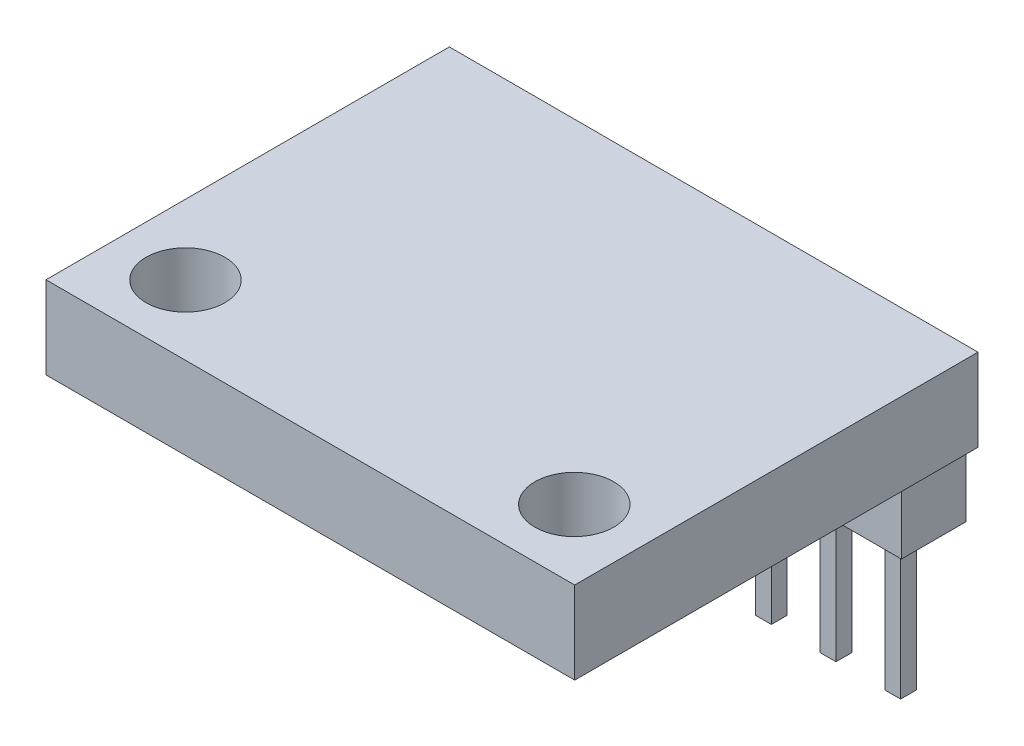
from build123d import *

# Parameters (mm, degrees)
SKETCH1_W           = 20.7772
SKETCH1_H           = 15.8496
SKETCH1_R           = 1.5494
BOSS_EXTRUDE2_DEPTH = 3.2385
SKETCH2_W           = 20.4978
SKETCH2_H           = 2.54
BOSS_EXTRUDE3_DEPTH = 2.4384
SKETCH3_W           = 0.6223
SKETCH3_H           = 0.6223
BOSS_EXTRUDE4_DEPTH = 5.7404


with BuildPart() as part:
    # Sketch1 → Boss-Extrude2 (new body)
    with BuildSketch(Plane(origin=(0, 0, 0), x_dir=(1, 0, 0), z_dir=(0, 1, 0))):
        with Locations((0, 0.7239)):
            Rectangle(SKETCH1_W, SKETCH1_H)
        with Locations((7.64032, -4.46786)):
            Circle(SKETCH1_R, mode=Mode.SUBTRACT)
        with Locations((-7.64032, -4.46786)):
            Circle(SKETCH1_R, mode=Mode.SUBTRACT)
    extrude(amount=BOSS_EXTRUDE2_DEPTH)

    # Sketch2 → Boss-Extrude3 (add)
    with BuildSketch(Plane(origin=(0, 0, 0), x_dir=(1, 0, 0), z_dir=(0, 1, 0))):
        with Locations((0, 7.0485)):
            Rectangle(SKETCH2_W, SKETCH2_H)
    extrude(amount=-BOSS_EXTRUDE3_DEPTH)

    # Sketch3 → Boss-Extrude4 (add)
    with BuildSketch(Plane.XZ.offset(2.4384)):
        with Locations((-6.29285, -7.0485)):
            Rectangle(SKETCH3_W, SKETCH3_H)
        with Locations((-8.83285, -7.0485)):
            Rectangle(SKETCH3_W, SKETCH3_H)
        with Locations((-3.75285, -7.0485)):
            Rectangle(SKETCH3_W, SKETCH3_H)
        with Locations((-1.21285, -7.0485)):
            Rectangle(SKETCH3_W, SKETCH3_H)
        with Locations((1.32715, -7.0485)):
            Rectangle(SKETCH3_W, SKETCH3_H)
        with Locations((3.86715, -7.0485)):
            Rectangle(SKETCH3_W, SKETCH3_H)
        with Locations((6.40715, -7.0485)):
            Rectangle(SKETCH3_W, SKETCH3_H)
        with Locations((8.94715, -7.0485)):
            Rectangle(SKETCH3_W, SKETCH3_H)
    extrude(amount=BOSS_EXTRUDE4_DEPTH)


solid = part.part
